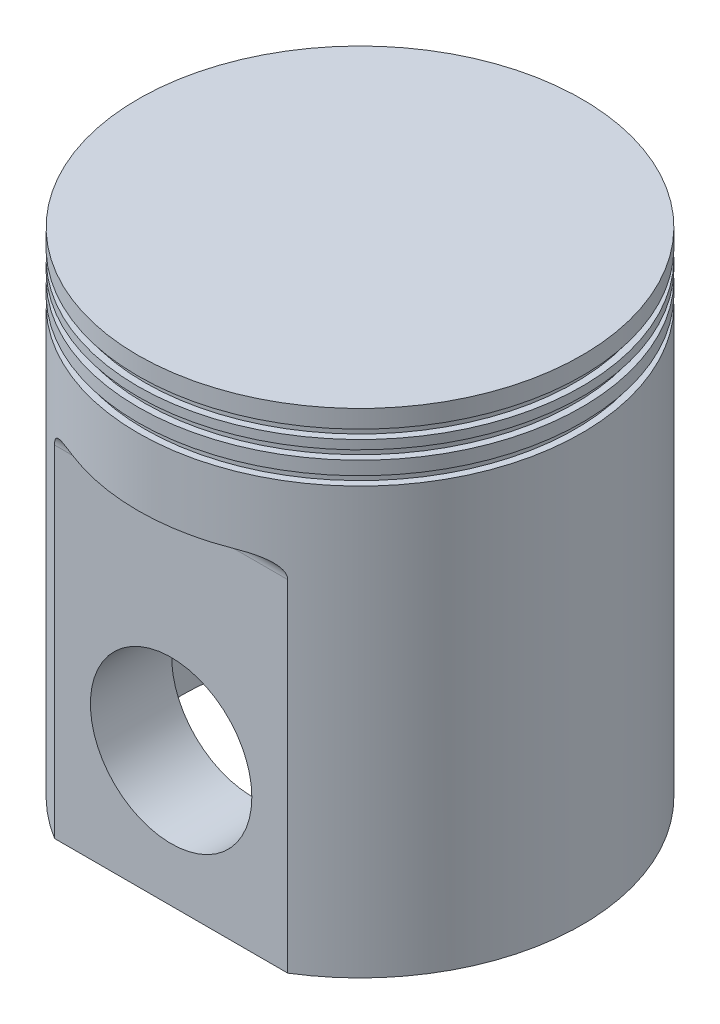
from build123d import *

# Parameters (mm, degrees)
SKICA3_R                      = 9
ODEBRAT_VYSUNUT_M1_DEPTH      = 25.75
ODEBRAT_VYSUNUT_M1_DEPTH_BACK = 25.75
ODEBRAT_VYSUNUT_M2_DEPTH      = 40
ZAOBLIT1_R                    = 2


with BuildPart() as part:
    # Skica2 → Rotovat1 (revolve)
    with BuildSketch(Plane.XY):
        Polygon((0, 0), (24.75, 0), (24.75, 47.5), (24, 47.5), (24, 48.5), (24.75, 48.5), (24.75, 50), (24, 50), (24, 51), (24.75, 51), (24.75, 52), (24, 52), (24, 53), (24.75, 53), (24.75, 55), (0, 55), align=None)
    revolve(axis=Axis((0, 49.551771463, 0), (0, -1, 0)))

    # Skica3 → Odebrat vysunutím1 (cut, two sides)
    with BuildSketch(Plane.XY) as odebrat_vysunut_m1_sk:
        with Locations((0, 15)):
            Circle(SKICA3_R)
    extrude(amount=ODEBRAT_VYSUNUT_M1_DEPTH, mode=Mode.SUBTRACT)
    extrude(odebrat_vysunut_m1_sk.sketch, amount=-ODEBRAT_VYSUNUT_M1_DEPTH_BACK, mode=Mode.SUBTRACT)

    # Skica4 → Odebrat vysunutím2 (cut)
    with BuildSketch(Plane.XZ):
        with BuildLine():
            Line((-13, 21.060923532), (13, 21.060923532))
            ThreePointArc((13, 21.060923532), (0, 24.75), (-13, 21.060923532))
        make_face()
        with BuildLine():
            ThreePointArc((15.686379442, 12), (19.75, 0), (15.686379442, -12))
            Line((15.686379442, -12), (-15.686379442, -12))
            ThreePointArc((-15.686379442, -12), (-19.75, 0), (-15.686379442, 12))
            Line((-15.686379442, 12), (15.686379442, 12))
        make_face()
        with BuildLine():
            Line((13, -21.060923532), (-13, -21.060923532))
            ThreePointArc((-13, -21.060923532), (0, -24.75), (13, -21.060923532))
        make_face()
    extrude(amount=-ODEBRAT_VYSUNUT_M2_DEPTH, mode=Mode.SUBTRACT)

    # Zaoblit1
    zaoblit1_edges = [part.edges().sort_by_distance(p)[0] for p in [
        (0, 40, 21.060923532),
        (0, 40, -12),
        (0, 40, 12),
        (19.75, 40, 0),
        (-19.75, 40, 0),
        (0, 40, -21.060923532),
    ]]
    fillet(zaoblit1_edges, radius=ZAOBLIT1_R)


solid = part.part
